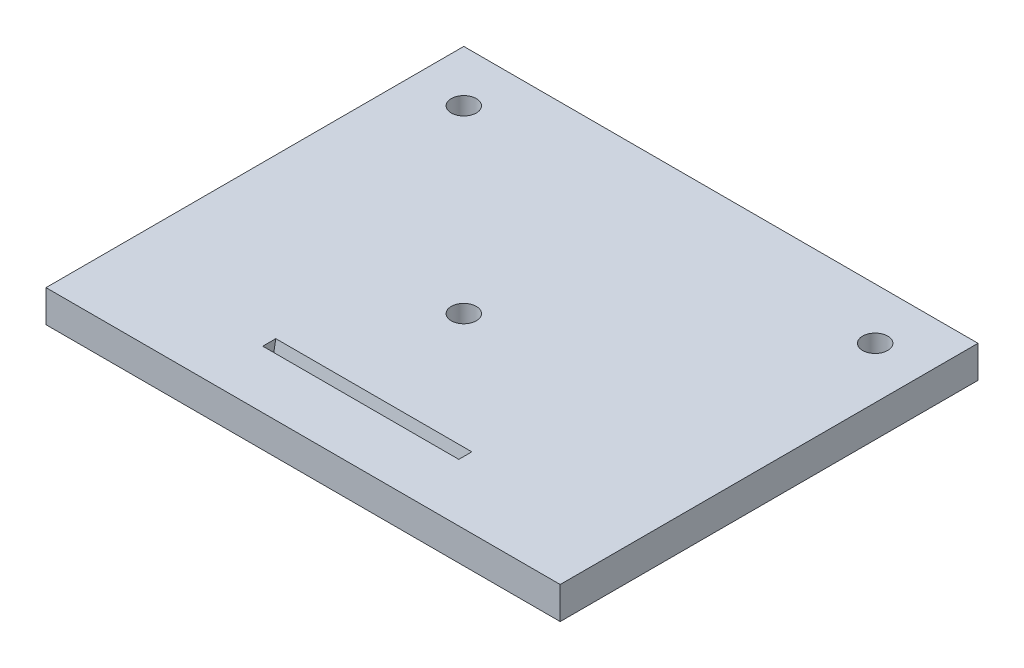
from build123d import *

# Parameters (mm, degrees)
ESQUISSE1_W                  = 80
ESQUISSE1_H                  = 65
BOSS_EXTRU_1_DEPTH           = 5
D_GAGEMENT_M3_51_D           = 3.9
ESQUISSE7_W                  = 30.5
ESQUISSE7_H                  = 2
ENL_V_MAT_EXTRU_1_DEPTH      = 5.924038765
ENL_V_MAT_EXTRU_1_DEPTH_BACK = 12.287131548


with BuildPart() as part:
    # Esquisse1 → Boss.-Extru.1 (new body)
    with BuildSketch(Plane(origin=(0, 0, 0), x_dir=(1, 0, 0), z_dir=(0, 1, 0))):
        with Locations((40, 32.5)):
            Rectangle(ESQUISSE1_W, ESQUISSE1_H)
    extrude(amount=BOSS_EXTRU_1_DEPTH)

    # Dégagement M3.51 (through all)
    with Locations(Plane(origin=(0, 5, 0), x_dir=(1, 0, 0), z_dir=(0, 1, 0))):
        with Locations((8, 57), (36, 29), (72, 57)):
            Hole(D_GAGEMENT_M3_51_D / 2)

    # Esquisse7 → Enlèv. mat.-Extru.1 (cut, two sides)
    with BuildSketch(Plane(origin=(0, 4.849231552, -0.855050358), x_dir=(-1, 0, 0), z_dir=(0, -0.984807753, 0.173648178))) as enl_v_mat_extru_1_sk:
        with Locations((-40, 8.964644395)):
            Rectangle(ESQUISSE7_W, ESQUISSE7_H)
    extrude(amount=ENL_V_MAT_EXTRU_1_DEPTH, mode=Mode.SUBTRACT)
    extrude(enl_v_mat_extru_1_sk.sketch, amount=-ENL_V_MAT_EXTRU_1_DEPTH_BACK, mode=Mode.SUBTRACT)


solid = part.part
